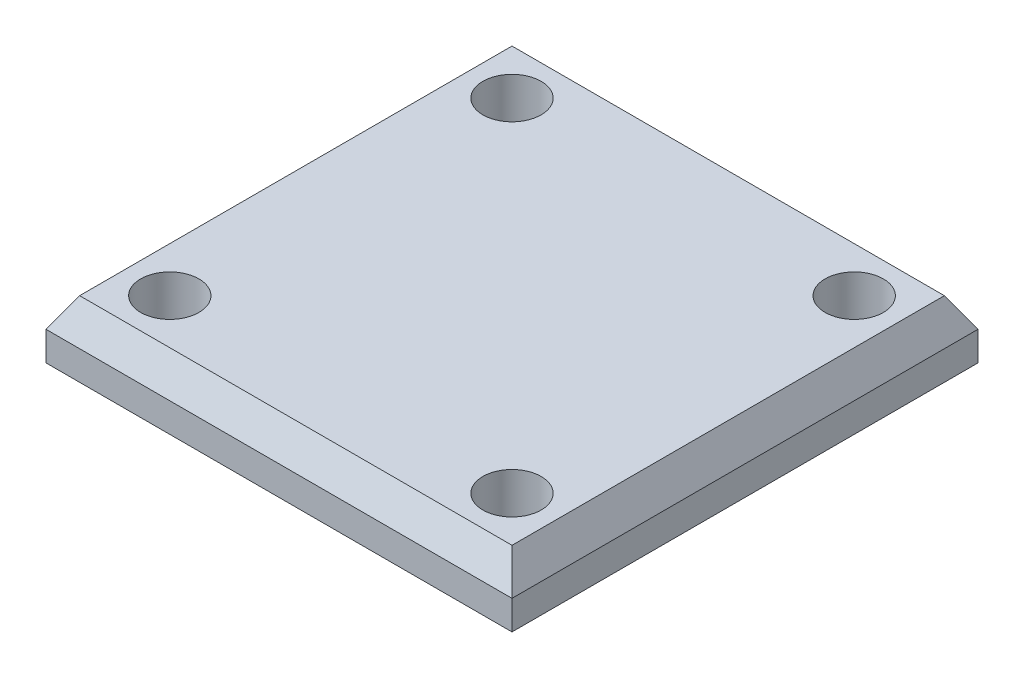
from build123d import *

# Parameters (mm, degrees)
SKETCH1_W             = 32
SKETCH1_H             = 32
BOSS_EXTRUDE1_DEPTH   = 4
SKETCH2_R             = 2
CUT_EXTRUDE1_DEPTH    = 3
CHAMFER1_SIZE         = 2
CHAMFER1_SIZE2        = 1.154700538
CHAMFER1_PART_2_SIZE  = 2
CHAMFER1_PART_2_SIZE2 = 1.154700538
CHAMFER1_PART_3_SIZE  = 2
CHAMFER1_PART_3_SIZE2 = 1.154700538
CHAMFER1_PART_4_SIZE  = 2
CHAMFER1_PART_4_SIZE2 = 1.154700538


with BuildPart() as part:
    # Sketch1 → Boss-Extrude1 (new body)
    with BuildSketch(Plane(origin=(0, 0, 0), x_dir=(1, 0, 0), z_dir=(0, 1, 0))):
        Rectangle(SKETCH1_W, SKETCH1_H)
    extrude(amount=BOSS_EXTRUDE1_DEPTH)

    # Sketch2 → Cut-Extrude1 (cut)
    with BuildSketch(Plane(origin=(0, 4, 0), x_dir=(1, 0, 0), z_dir=(0, 1, 0))):
        with Locations((-11.75, 11.75)):
            Circle(SKETCH2_R)
        with Locations((11.75, 11.75)):
            Circle(SKETCH2_R)
        with Locations((11.75, -11.75)):
            Circle(SKETCH2_R)
        with Locations((-11.75, -11.75)):
            Circle(SKETCH2_R)
    extrude(amount=-CUT_EXTRUDE1_DEPTH, mode=Mode.SUBTRACT)

    # Chamfer1
    chamfer1_edges = [part.edges().sort_by_distance(p)[0] for p in [
        (-16, 4, 0),
    ]]
    chamfer1_side = [part.faces().sort_by_distance(p)[0] for p in [
        (-16, 2, 0),
    ]]
    chamfer(chamfer1_edges, length=CHAMFER1_SIZE, length2=CHAMFER1_SIZE2, reference=chamfer1_side[0])

    # Chamfer1 part 2
    chamfer1_part_2_edges = [part.edges().sort_by_distance(p)[0] for p in [
        (0, 4, 16),
    ]]
    chamfer1_part_2_side = [part.faces().sort_by_distance(p)[0] for p in [
        (0, 2, 16),
    ]]
    chamfer(chamfer1_part_2_edges, length=CHAMFER1_PART_2_SIZE, length2=CHAMFER1_PART_2_SIZE2, reference=chamfer1_part_2_side[0])

    # Chamfer1 part 3
    chamfer1_part_3_edges = [part.edges().sort_by_distance(p)[0] for p in [
        (16, 4, 0),
    ]]
    chamfer1_part_3_side = [part.faces().sort_by_distance(p)[0] for p in [
        (16, 2, 0),
    ]]
    chamfer(chamfer1_part_3_edges, length=CHAMFER1_PART_3_SIZE, length2=CHAMFER1_PART_3_SIZE2, reference=chamfer1_part_3_side[0])

    # Chamfer1 part 4
    chamfer1_part_4_edges = [part.edges().sort_by_distance(p)[0] for p in [
        (0, 4, -16),
    ]]
    chamfer1_part_4_side = [part.faces().sort_by_distance(p)[0] for p in [
        (0, 2, -16),
    ]]
    chamfer(chamfer1_part_4_edges, length=CHAMFER1_PART_4_SIZE, length2=CHAMFER1_PART_4_SIZE2, reference=chamfer1_part_4_side[0])


solid = part.part
